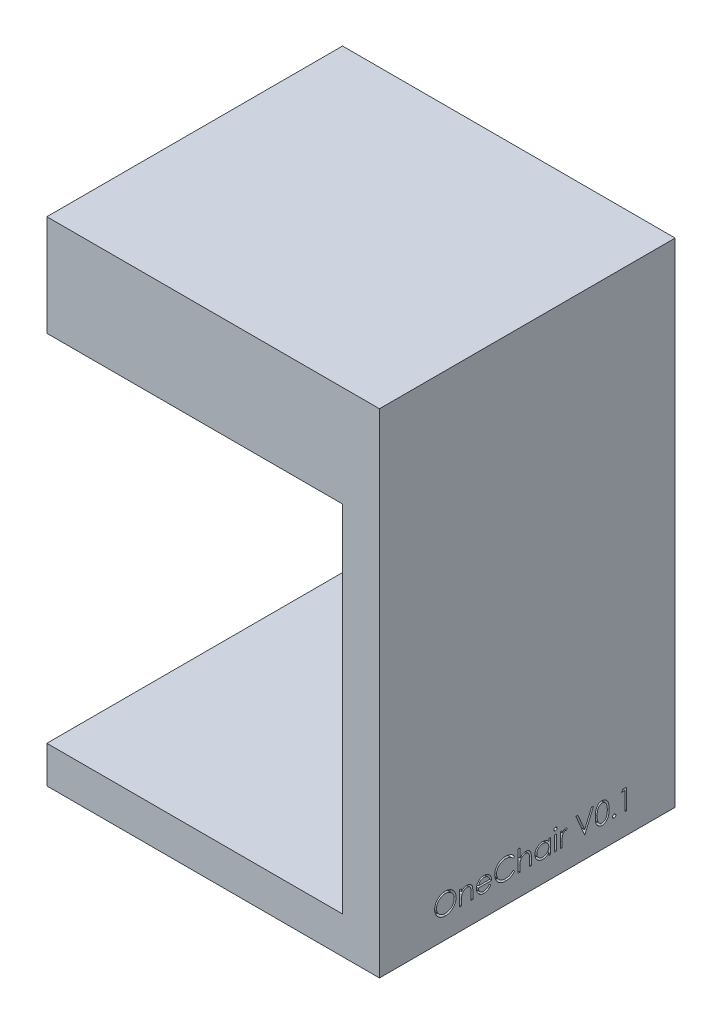
from build123d import *

# Parameters (mm, degrees)
SKETCH1_W           = 50.8
SKETCH1_H           = 50.8
BOSS_EXTRUDE1_DEPTH = 6.35
SKETCH2_W           = 6.35
SKETCH2_H           = 50.8
BOSS_EXTRUDE3_DEPTH = 6.35
SKETCH3_W           = 6.35
SKETCH3_H           = 50.8
BOSS_EXTRUDE4_DEPTH = 61
SKETCH4_W           = 57.15
SKETCH4_H           = 50.8
BOSS_EXTRUDE5_DEPTH = 11
SKETCH7_W           = 57.15
SKETCH7_H           = 50.8
BOSS_EXTRUDE7_DEPTH = 6.35
SKETCH11_W          = 0.314102564
SKETCH11_H          = 2.557692307
CUT_EXTRUDE3_DEPTH  = 1


with BuildPart() as part:
    # Sketch1 → Boss-Extrude1 (new body)
    with BuildSketch(Plane(origin=(0, 0, 0), x_dir=(1, 0, 0), z_dir=(0, 1, 0))):
        Rectangle(SKETCH1_W, SKETCH1_H)
    extrude(amount=BOSS_EXTRUDE1_DEPTH)

    # Sketch2 → Boss-Extrude3 (add)
    with BuildSketch(Plane(origin=(0, 0, 0), x_dir=(1, 0, 0), z_dir=(0, 1, 0))):
        with Locations((28.575, 0)):
            Rectangle(SKETCH2_W, SKETCH2_H)
    extrude(amount=BOSS_EXTRUDE3_DEPTH)

    # Sketch3 → Boss-Extrude4 (add)
    with BuildSketch(Plane(origin=(0, 6.35, 0), x_dir=(1, 0, 0), z_dir=(0, 1, 0))):
        with Locations((28.575, 0)):
            Rectangle(SKETCH3_W, SKETCH3_H)
    extrude(amount=BOSS_EXTRUDE4_DEPTH)

    # Sketch4 → Boss-Extrude5 (add)
    with BuildSketch(Plane(origin=(0, 67.35, 0), x_dir=(1, 0, 0), z_dir=(0, 1, 0))):
        with Locations((3.175, 0)):
            Rectangle(SKETCH4_W, SKETCH4_H)
    extrude(amount=BOSS_EXTRUDE5_DEPTH)

    # Sketch7 → Boss-Extrude7 (add)
    with BuildSketch(Plane(origin=(0, 78.35, 0), x_dir=(1, 0, 0), z_dir=(0, 1, 0))):
        with Locations((3.175, 0)):
            Rectangle(SKETCH7_W, SKETCH7_H)
    extrude(amount=BOSS_EXTRUDE7_DEPTH)

    # Sketch11 → Cut-Extrude3 (cut)
    with BuildSketch(Plane(origin=(31.75, 0, 0), x_dir=(0, 0, -1), z_dir=(1, 0, 0))):
        with BuildLine():
            add(Edge.make_bspline(
                [(-14.101398787, 7.268560163), (-14.036590681, 7.266918684), (-13.909302214, 7.263694683), (-13.722227316, 7.23901558), (-13.543632221, 7.19632019), (-13.372062082, 7.139457207), (-13.209569105, 7.063602822), (-13.054930213, 6.971917673), (-12.908513339, 6.863441215), (-12.772291958, 6.739011988), (-12.647635007, 6.603628534), (-12.537809121, 6.459150624), (-12.445766827, 6.306451822), (-12.37018104, 6.145990991), (-12.31088243, 5.978131023), (-12.269963387, 5.80197702), (-12.243825237, 5.61867033), (-12.240769459, 5.493643465), (-12.239219299, 5.430218817)],
                knots=[0, 0, 0, 0, 0.000194393, 0.000381804, 0.00056479, 0.000744601, 0.000923091, 0.001101652, 0.001283106, 0.001468738, 0.001654324, 0.001834514, 0.002012231, 0.002188181, 0.002365797, 0.002545211, 0.002729936, 0.002920126, 0.002920126, 0.002920126, 0.002920126], degree=3))
            add(Edge.make_bspline(
                [(-12.239219299, 5.430218817), (-12.240769232, 5.367261371), (-12.243824329, 5.243164951), (-12.269993106, 5.061021506), (-12.311034106, 4.88593081), (-12.369630372, 4.718185157), (-12.444855851, 4.557607593), (-12.537511022, 4.404620639), (-12.646652233, 4.259174141), (-12.770859084, 4.122861476), (-12.906260126, 3.997864005), (-13.051490392, 3.888945129), (-13.203283712, 3.795221005), (-13.363593421, 3.720437331), (-13.530293457, 3.66066541), (-13.70487578, 3.61991278), (-13.886522335, 3.593625737), (-14.010393338, 3.590607221), (-14.073353915, 3.589072984)],
                knots=[0, 0, 0, 0, 0.000188789, 0.000372126, 0.000550857, 0.00072758, 0.000904164, 0.001081881, 0.001263191, 0.001448823, 0.00163441, 0.001815159, 0.001992641, 0.002168591, 0.002344885, 0.002522934, 0.002705576, 0.002894365, 0.002894365, 0.002894365, 0.002894365], degree=3))
            add(Edge.make_bspline(
                [(-14.073353915, 3.589072984), (-14.136778234, 3.590622371), (-14.26180445, 3.593676625), (-14.445341485, 3.61985803), (-14.621619229, 3.660799333), (-14.79013358, 3.71930877), (-14.95097851, 3.794926), (-15.104468593, 3.887130379), (-15.24998774, 3.996537521), (-15.386329486, 4.120704095), (-15.511078684, 4.255875647), (-15.61983806, 4.400709902), (-15.712063173, 4.552365359), (-15.787426506, 4.711262883), (-15.847090965, 4.876634326), (-15.887795783, 5.049582803), (-15.914131736, 5.229122309), (-15.917166582, 5.351365207), (-15.918706479, 5.413391894)],
                knots=[0, 0, 0, 0, 0.00019019, 0.000374915, 0.000555011, 0.000732396, 0.00090898, 0.001087298, 0.001268608, 0.00145424, 0.001639827, 0.001819595, 0.001996712, 0.002171394, 0.002346367, 0.002523053, 0.002703612, 0.002889599, 0.002889599, 0.002889599, 0.002889599], degree=3))
            add(Edge.make_bspline(
                [(-15.918706479, 5.413391894), (-15.918171843, 5.455024563), (-15.917109317, 5.537764687), (-15.904317625, 5.660631287), (-15.885755923, 5.781521945), (-15.859154011, 5.900092893), (-15.824362344, 6.016053877), (-15.783310317, 6.13020464), (-15.733170471, 6.241388364), (-15.676489823, 6.350131756), (-15.613228015, 6.454739662), (-15.543352266, 6.553619245), (-15.469316897, 6.647600242), (-15.388153504, 6.734247245), (-15.302537058, 6.816080902), (-15.21107868, 6.891843619), (-15.114336436, 6.96221857), (-15.011894056, 7.025638911), (-14.906275781, 7.082998045), (-14.797399003, 7.132219896), (-14.686742432, 7.174465958), (-14.573787784, 7.208706783), (-14.458835012, 7.235738819), (-14.341633227, 7.254146173), (-14.222275801, 7.266970491), (-14.141864482, 7.268027993), (-14.101398787, 7.268560163)],
                knots=[0, 0, 0, 0, 0.000124849, 0.000248123, 0.000370193, 0.00049164, 0.000612319, 0.000733199, 0.000855287, 0.000977905, 0.001100913, 0.001221706, 0.001340948, 0.001459521, 0.001577551, 0.001696047, 0.001815534, 0.001936153, 0.002057243, 0.002175846, 0.002294342, 0.002412335, 0.002529682, 0.00264829, 0.002768075, 0.00288942, 0.00288942, 0.00288942, 0.00288942], degree=3))
        make_face()
        with BuildLine():
            add(Edge.make_bspline(
                [(-14.085974107, 6.909585804), (-14.119188741, 6.909180914), (-14.185300474, 6.908375004), (-14.28358501, 6.897759289), (-14.380576944, 6.8826294), (-14.476296306, 6.861047879), (-14.570342595, 6.831643826), (-14.663592436, 6.797802918), (-14.75519549, 6.756581828), (-14.844849348, 6.710009123), (-14.931764423, 6.658460202), (-15.013777125, 6.601488435), (-15.091099769, 6.540429881), (-15.163543035, 6.475142044), (-15.230894208, 6.405292442), (-15.294478909, 6.331940006), (-15.351748491, 6.252988115), (-15.404234068, 6.170577708), (-15.451201908, 6.084816127), (-15.492967263, 5.996606265), (-15.527131271, 5.905228578), (-15.554993648, 5.81167442), (-15.578093458, 5.71609196), (-15.592727383, 5.617756112), (-15.603459742, 5.517161), (-15.604219587, 5.449179146), (-15.604603915, 5.414794138)],
                knots=[0, 0, 0, 0, 9.9599e-05, 0.000198245, 0.000296222, 0.00039402, 0.00049227, 0.000591646, 0.000691452, 0.000793368, 0.000894612, 0.000994383, 0.001092713, 0.00119001, 0.001286696, 0.001383657, 0.001480979, 0.001579008, 0.001676595, 0.001774142, 0.001871547, 0.001968922, 0.002066879, 0.00216624, 0.00226698, 0.002370083, 0.002370083, 0.002370083, 0.002370083], degree=3))
            add(Edge.make_bspline(
                [(-15.604603915, 5.414794138), (-15.603329053, 5.364231917), (-15.600821005, 5.264760387), (-15.578863435, 5.118992243), (-15.54504146, 4.978903957), (-15.495184094, 4.845262047), (-15.432833479, 4.716917764), (-15.355806589, 4.59500966), (-15.264547504, 4.479504785), (-15.160883977, 4.371209516), (-15.04756127, 4.272363712), (-14.92722854, 4.185600303), (-14.801174933, 4.112190054), (-14.66907173, 4.052384981), (-14.531624191, 4.004995243), (-14.38794664, 3.972516612), (-14.238996181, 3.951141157), (-14.137465525, 3.949088401), (-14.085974107, 3.948047343)],
                knots=[0, 0, 0, 0, 0.000151605, 0.000298253, 0.000441263, 0.000583229, 0.000725274, 0.000868635, 0.001014928, 0.001166177, 0.001317744, 0.00146543, 0.001610576, 0.001754594, 0.001899821, 0.002045914, 0.002195936, 0.002350312, 0.002350312, 0.002350312, 0.002350312], degree=3))
            add(Edge.make_bspline(
                [(-14.085974107, 3.948047343), (-14.051364606, 3.948522847), (-13.982723569, 3.949465915), (-13.880628047, 3.958964592), (-13.780371835, 3.974196462), (-13.682095555, 3.996127117), (-13.585910744, 4.023574324), (-13.491415941, 4.056182052), (-13.39961765, 4.096863255), (-13.309357813, 4.141811207), (-13.222961571, 4.193051364), (-13.140486039, 4.248089514), (-13.064010059, 4.309058135), (-12.991620987, 4.373375947), (-12.923993298, 4.442339795), (-12.861584314, 4.515860017), (-12.804604182, 4.594400674), (-12.752138535, 4.67668608), (-12.705335273, 4.762682333), (-12.664556174, 4.851212011), (-12.629960058, 4.94205712), (-12.602031553, 5.035348691), (-12.580146091, 5.13090954), (-12.565066171, 5.228867618), (-12.554517733, 5.329026961), (-12.553722655, 5.396770817), (-12.553321864, 5.430919939)],
                knots=[0, 0, 0, 0, 0.000103804, 0.000205874, 0.000307314, 0.000407849, 0.000507719, 0.000607281, 0.000707445, 0.000808723, 0.000909609, 0.001008589, 0.001105934, 0.001202762, 0.001298946, 0.001395452, 0.001491794, 0.001589823, 0.001688026, 0.001785277, 0.001882027, 0.001979402, 0.0020772, 0.002175869, 0.002276609, 0.002379011, 0.002379011, 0.002379011, 0.002379011], degree=3))
            add(Edge.make_bspline(
                [(-12.553321864, 5.430919939), (-12.553722977, 5.464835443), (-12.554518658, 5.532113094), (-12.565061133, 5.631573912), (-12.580162023, 5.728827123), (-12.601924731, 5.823490926), (-12.629974885, 5.915589451), (-12.664562215, 6.005036199), (-12.705347515, 6.092164394), (-12.752155739, 6.176758691), (-12.804771563, 6.257933429), (-12.862265806, 6.335535842), (-12.925631154, 6.408108583), (-12.993057179, 6.477443277), (-13.066228064, 6.542061167), (-13.144812358, 6.601983687), (-13.227856036, 6.658656962), (-13.315783271, 6.709782523), (-13.406527225, 6.756996756), (-13.499641183, 6.797447759), (-13.594070283, 6.831819879), (-13.689574395, 6.861136844), (-13.786957373, 6.882544874), (-13.885561202, 6.897772924), (-13.985249461, 6.90837131), (-14.052292681, 6.909179688), (-14.085974107, 6.909585804)],
                knots=[0, 0, 0, 0, 0.000101701, 0.000201743, 0.00029972, 0.000396835, 0.000492868, 0.000588308, 0.000684288, 0.000781261, 0.000878109, 0.000974304, 0.001070733, 0.001166917, 0.001264269, 0.001363274, 0.001463228, 0.001565678, 0.001668217, 0.001769947, 0.001869982, 0.001969573, 0.002069423, 0.002168785, 0.002268827, 0.002369827, 0.002369827, 0.002369827, 0.002369827], degree=3))
        make_face(mode=Mode.SUBTRACT)
        with BuildLine():
            Line((-11.611014171, 6.236508881), (-11.296911607, 6.236508881))
            Line((-11.296911607, 6.236508881), (-11.296911607, 5.77517074))
            add(Edge.make_bspline(
                [(-11.296911607, 5.77517074), (-11.263373972, 5.817013463), (-11.198293021, 5.898210727), (-11.089908688, 6.004931301), (-10.975364787, 6.092876526), (-10.855362784, 6.16298032), (-10.729739774, 6.215826946), (-10.599261504, 6.253992877), (-10.463146798, 6.276877706), (-10.370582361, 6.279867936), (-10.323754556, 6.281380676)],
                knots=[0, 0, 0, 0, 0.000160777, 0.000311994, 0.000455029, 0.000592958, 0.000727738, 0.000862858, 0.001000022, 0.001140458, 0.001140458, 0.001140458, 0.001140458], degree=3))
            add(Edge.make_bspline(
                [(-10.323754556, 6.281380676), (-10.276423922, 6.279635481), (-10.183786454, 6.276219712), (-10.048908393, 6.249203021), (-9.922934999, 6.203057766), (-9.806315443, 6.139845696), (-9.70118823, 6.061239222), (-9.608863378, 5.969661441), (-9.532500131, 5.864325357), (-9.481302768, 5.766602201), (-9.44757712, 5.679913407), (-9.426344783, 5.605666657), (-9.408313801, 5.522948506), (-9.392682053, 5.432008917), (-9.382104941, 5.332210726), (-9.37376265, 5.223963034), (-9.367783956, 5.107300904), (-9.367546749, 5.026614276), (-9.367424428, 4.985006478)],
                knots=[0, 0, 0, 0, 0.00014192, 0.000277771, 0.000410631, 0.000543023, 0.000674273, 0.000803173, 0.000931629, 0.001063031, 0.00113295, 0.001210382, 0.001294414, 0.001386856, 0.001487045, 0.001595345, 0.001712567, 0.001837375, 0.001837375, 0.001837375, 0.001837375], degree=3))
            Line((-9.367424428, 4.985006478), (-9.367424428, 3.678816574))
            Line((-9.367424428, 3.678816574), (-9.681526992, 3.678816574))
            Line((-9.681526992, 3.678816574), (-9.681526992, 4.881941574))
            add(Edge.make_bspline(
                [(-9.681526992, 4.881941574), (-9.6817202, 4.916764019), (-9.682089774, 4.983373429), (-9.683255421, 5.078742453), (-9.686065227, 5.165229031), (-9.69001354, 5.242626398), (-9.695792571, 5.310860235), (-9.701815202, 5.370069512), (-9.709180179, 5.420179054), (-9.715743092, 5.450344137), (-9.718686447, 5.463872663)],
                knots=[0, 0, 0, 0, 0.00010447, 0.000199832, 0.000286116, 0.000364054, 0.000432294, 0.000491525, 0.000542592, 0.000584118, 0.000584118, 0.000584118, 0.000584118], degree=3))
            add(Edge.make_bspline(
                [(-9.718686447, 5.463872663), (-9.729311978, 5.503583848), (-9.749762839, 5.580015593), (-9.800296822, 5.683689946), (-9.864111003, 5.771888133), (-9.942008852, 5.844064855), (-10.033237928, 5.900235692), (-10.137545071, 5.939209647), (-10.253923711, 5.963585916), (-10.335778094, 5.966013048), (-10.378442056, 5.967278112)],
                knots=[0, 0, 0, 0, 0.000123096, 0.000236922, 0.000343781, 0.000447968, 0.000553428, 0.000663063, 0.000780492, 0.000908329, 0.000908329, 0.000908329, 0.000908329], degree=3))
            add(Edge.make_bspline(
                [(-10.378442056, 5.967278112), (-10.40370974, 5.966802108), (-10.453713833, 5.965860107), (-10.527863804, 5.956408809), (-10.599787978, 5.940950353), (-10.670208187, 5.920081715), (-10.73771598, 5.891419446), (-10.804480272, 5.858890076), (-10.867987036, 5.818341864), (-10.929590433, 5.773151243), (-10.98690324, 5.723072035), (-11.040231579, 5.670227525), (-11.087769599, 5.613951921), (-11.130838274, 5.555151974), (-11.168016538, 5.493020136), (-11.200469626, 5.428155829), (-11.228005321, 5.360473681), (-11.241688013, 5.313498619), (-11.248534203, 5.289994458)],
                knots=[0, 0, 0, 0, 7.5773e-05, 0.000149953, 0.000223797, 0.000296325, 0.00036989, 0.000443574, 0.000518859, 0.000595564, 0.000672601, 0.000746967, 0.000820581, 0.000893366, 0.000965391, 0.001037508, 0.001110807, 0.001184211, 0.001184211, 0.001184211, 0.001184211], degree=3))
            add(Edge.make_bspline(
                [(-11.248534203, 5.289994458), (-11.252473852, 5.272739255), (-11.261050261, 5.235175581), (-11.270313441, 5.173531161), (-11.278721016, 5.102221186), (-11.285757975, 5.021328869), (-11.290063391, 4.930570994), (-11.294757788, 4.830335157), (-11.296466849, 4.720221668), (-11.296759203, 4.643559975), (-11.296911607, 4.603596221)],
                knots=[0, 0, 0, 0, 5.3082e-05, 0.000115557, 0.000186868, 0.0002685, 0.000359077, 0.000459426, 0.000569522, 0.000689416, 0.000689416, 0.000689416, 0.000689416], degree=3))
            Line((-11.296911607, 4.603596221), (-11.296911607, 3.678816574))
            Line((-11.296911607, 3.678816574), (-11.611014171, 3.678816574))
            Line((-11.611014171, 3.678816574), (-11.611014171, 6.236508881))
        make_face()
        with BuildLine():
            Line((-6.550317056, 4.486508881), (-6.271270582, 4.339974426))
            add(Edge.make_bspline(
                [(-6.271270582, 4.339974426), (-6.293507177, 4.300531095), (-6.336770785, 4.223789992), (-6.411171533, 4.118358132), (-6.489163606, 4.023510416), (-6.574267574, 3.941780762), (-6.663937253, 3.870529377), (-6.758669907, 3.808191552), (-6.858958725, 3.755073032), (-6.96480845, 3.710320504), (-7.077108001, 3.67591101), (-7.196129518, 3.651606789), (-7.322101013, 3.63658352), (-7.408447193, 3.634838379), (-7.452660806, 3.633944779)],
                knots=[0, 0, 0, 0, 0.000135759, 0.000264133, 0.000386579, 0.000503597, 0.000617365, 0.000729763, 0.000843304, 0.000957371, 0.001074023, 0.001195027, 0.001321389, 0.001453992, 0.001453992, 0.001453992, 0.001453992], degree=3))
            add(Edge.make_bspline(
                [(-7.452660806, 3.633944779), (-7.501802783, 3.635091954), (-7.597664545, 3.637329761), (-7.737204292, 3.656622225), (-7.868583711, 3.688094584), (-7.991795414, 3.732060126), (-8.106537667, 3.78948745), (-8.213038521, 3.859446931), (-8.311858047, 3.941579186), (-8.399882256, 4.03659563), (-8.479126139, 4.138277587), (-8.549051959, 4.244233471), (-8.60750939, 4.354196696), (-8.655062, 4.46746722), (-8.693466865, 4.583331113), (-8.720233569, 4.702842581), (-8.735663317, 4.825678165), (-8.738027763, 4.908775501), (-8.739219299, 4.95065151)],
                knots=[0, 0, 0, 0, 0.000147371, 0.000287478, 0.000421649, 0.000552053, 0.000679042, 0.000805636, 0.000933558, 0.00106351, 0.001193382, 0.001319977, 0.001443869, 0.001566405, 0.001688128, 0.001809576, 0.001933238, 0.002058864, 0.002058864, 0.002058864, 0.002058864], degree=3))
            add(Edge.make_bspline(
                [(-8.739219299, 4.95065151), (-8.738160158, 4.98994634), (-8.73606108, 5.067823505), (-8.722830293, 5.183089049), (-8.699381999, 5.295117502), (-8.667205676, 5.40400195), (-8.625654429, 5.509560084), (-8.57482221, 5.611856147), (-8.514629832, 5.710781287), (-8.468157159, 5.773184421), (-8.444748146, 5.804617856)],
                knots=[0, 0, 0, 0, 0.000117891, 0.000233644, 0.000347498, 0.000460856, 0.000573868, 0.000687374, 0.000803169, 0.000920699, 0.000920699, 0.000920699, 0.000920699], degree=3))
            add(Edge.make_bspline(
                [(-8.444748146, 5.804617856), (-8.413040463, 5.842486726), (-8.350629516, 5.917024876), (-8.245073161, 6.014963202), (-8.130772965, 6.097006977), (-8.009161338, 6.165014113), (-7.878824864, 6.21668776), (-7.741515573, 6.255195343), (-7.595669987, 6.276773354), (-7.495964766, 6.279821187), (-7.444948466, 6.281380676)],
                knots=[0, 0, 0, 0, 0.000148071, 0.000291452, 0.00043058, 0.000569298, 0.000708346, 0.00085021, 0.000996268, 0.001149307, 0.001149307, 0.001149307, 0.001149307], degree=3))
            add(Edge.make_bspline(
                [(-7.444948466, 6.281380676), (-7.392500861, 6.280026627), (-7.289610615, 6.277370292), (-7.139578494, 6.252743959), (-6.997617777, 6.213691404), (-6.863785273, 6.158537614), (-6.738067412, 6.087378062), (-6.621281363, 5.99923622), (-6.51142985, 5.896818133), (-6.447521271, 5.818054924), (-6.415000549, 5.777975228)],
                knots=[0, 0, 0, 0, 0.000157241, 0.00030847, 0.000454763, 0.000598116, 0.000741606, 0.000886879, 0.001036172, 0.001190853, 0.001190853, 0.001190853, 0.001190853], degree=3))
            add(Edge.make_bspline(
                [(-6.415000549, 5.777975228), (-6.392873611, 5.747771646), (-6.348767018, 5.687565527), (-6.293519918, 5.58939437), (-6.245562523, 5.486683776), (-6.207229562, 5.377773479), (-6.176190061, 5.263953899), (-6.153733242, 5.144411354), (-6.140563624, 5.019181443), (-6.137974926, 4.933854887), (-6.136655197, 4.890355035)],
                knots=[0, 0, 0, 0, 0.000112234, 0.000223721, 0.000337279, 0.000451932, 0.000569628, 0.000690912, 0.000816421, 0.00094695, 0.00094695, 0.00094695, 0.00094695], degree=3))
            Line((-6.136655197, 4.890355035), (-8.425116735, 4.890355035))
            add(Edge.make_bspline(
                [(-8.425116735, 4.890355035), (-8.423577129, 4.856654571), (-8.420549555, 4.790383967), (-8.406434412, 4.693413184), (-8.384185638, 4.601039842), (-8.352916575, 4.5139568), (-8.31504973, 4.431026673), (-8.268664013, 4.352864636), (-8.213324459, 4.279826705), (-8.15159876, 4.211259568), (-8.082891665, 4.150198807), (-8.010608918, 4.09554703), (-7.933715353, 4.049741434), (-7.852817269, 4.012561544), (-7.768045484, 3.983455228), (-7.679373289, 3.963587407), (-7.586975172, 3.9502803), (-7.523989438, 3.948800635), (-7.491923626, 3.948047343)],
                knots=[0, 0, 0, 0, 0.000101159, 0.000198924, 0.000293472, 0.000385722, 0.000476069, 0.000566611, 0.000657757, 0.000750573, 0.000842919, 0.000933083, 0.001022062, 0.001110842, 0.001199752, 0.001290403, 0.001383113, 0.001479259, 0.001479259, 0.001479259, 0.001479259], degree=3))
            add(Edge.make_bspline(
                [(-7.491923626, 3.948047343), (-7.460572479, 3.9486554), (-7.398365788, 3.949861901), (-7.305724931, 3.961593812), (-7.214585403, 3.980564087), (-7.12532442, 4.006454077), (-7.039753574, 4.038030929), (-6.960508024, 4.076133787), (-6.887627808, 4.118283534), (-6.819510842, 4.166493209), (-6.753439848, 4.225501396), (-6.687897362, 4.299137117), (-6.617620709, 4.386224645), (-6.573631116, 4.451770311), (-6.550317056, 4.486508881)],
                knots=[0, 0, 0, 0, 9.4016e-05, 0.000186545, 0.000279636, 0.000373054, 0.000465125, 0.000552934, 0.000636508, 0.000717442, 0.000802858, 0.000901616, 0.001012865, 0.001138311, 0.001138311, 0.001138311, 0.001138311], degree=3))
        make_face()
        with BuildLine():
            add(Edge.make_bspline(
                [(-6.450757761, 5.204457599), (-6.462254386, 5.246120473), (-6.484381687, 5.326308094), (-6.530618052, 5.437348984), (-6.582689592, 5.536036885), (-6.644311324, 5.621616518), (-6.714130049, 5.697620031), (-6.794775232, 5.764038616), (-6.885211125, 5.823456067), (-6.984970266, 5.873608567), (-7.090612051, 5.916298426), (-7.201218243, 5.944923541), (-7.314076031, 5.964533084), (-7.390410317, 5.966359192), (-7.428822665, 5.967278112)],
                knots=[0, 0, 0, 0, 0.000129543, 0.000249328, 0.000360065, 0.000463575, 0.000564789, 0.000668832, 0.000776175, 0.000888744, 0.001003316, 0.001117263, 0.001230914, 0.001346035, 0.001346035, 0.001346035, 0.001346035], degree=3))
            add(Edge.make_bspline(
                [(-7.428822665, 5.967278112), (-7.460172103, 5.966666441), (-7.522143352, 5.965457295), (-7.613444421, 5.953987165), (-7.70112412, 5.93502732), (-7.785829407, 5.909062364), (-7.866450276, 5.874453761), (-7.944645044, 5.833870535), (-8.01842544, 5.784328951), (-8.064566735, 5.746570096), (-8.087877152, 5.727494458)],
                knots=[0, 0, 0, 0, 9.4016e-05, 0.000185849, 0.000275511, 0.000362884, 0.000451173, 0.00053836, 0.000626838, 0.000717174, 0.000717174, 0.000717174, 0.000717174], degree=3))
            add(Edge.make_bspline(
                [(-8.087877152, 5.727494458), (-8.104570434, 5.712400143), (-8.138353568, 5.681852927), (-8.18349409, 5.62922372), (-8.226714562, 5.572472158), (-8.266048215, 5.509427033), (-8.302125802, 5.440806254), (-8.335885779, 5.367188619), (-8.366272191, 5.288015489), (-8.383368301, 5.23284305), (-8.392164011, 5.204457599)],
                knots=[0, 0, 0, 0, 6.7454e-05, 0.00013651, 0.000207604, 0.000281328, 0.000359112, 0.000440057, 0.000524171, 0.000613305, 0.000613305, 0.000613305, 0.000613305], degree=3))
            Line((-8.392164011, 5.204457599), (-6.450757761, 5.204457599))
        make_face(mode=Mode.SUBTRACT)
        with BuildLine():
            Line((-2.187937248, 6.53658901), (-2.462776992, 6.326252471))
            add(Edge.make_bspline(
                [(-2.462776992, 6.326252471), (-2.48238288, 6.349618441), (-2.521330327, 6.396035357), (-2.58398953, 6.461214901), (-2.649291172, 6.522280163), (-2.717210294, 6.579522042), (-2.788969413, 6.630938808), (-2.862830212, 6.679209911), (-2.940028257, 6.722477649), (-3.046779992, 6.774940635), (-3.18642784, 6.82968679), (-3.362222679, 6.875590021), (-3.545733777, 6.904811197), (-3.670931377, 6.907976038), (-3.734611928, 6.909585804)],
                knots=[0, 0, 0, 0, 9.1485e-05, 0.000181737, 0.000271024, 0.000359627, 0.000447979, 0.000535687, 0.000624217, 0.000713268, 0.000892422, 0.00107303, 0.001257466, 0.001448389, 0.001448389, 0.001448389, 0.001448389], degree=3))
            add(Edge.make_bspline(
                [(-3.734611928, 6.909585804), (-3.769695227, 6.909181842), (-3.83953622, 6.908377666), (-3.943184693, 6.897768541), (-4.044897744, 6.882857331), (-4.14460921, 6.860732008), (-4.242192169, 6.832759389), (-4.338284571, 6.799333975), (-4.431495171, 6.757979135), (-4.523113409, 6.712270875), (-4.61089262, 6.66064343), (-4.693947668, 6.604330078), (-4.771975636, 6.543960982), (-4.845038248, 6.479309875), (-4.913210196, 6.410667915), (-4.975997507, 6.337303573), (-5.033182917, 6.2594514), (-5.085899942, 6.178137992), (-5.133112676, 6.093600201), (-5.172642555, 6.00552513), (-5.207647677, 5.915421027), (-5.23534692, 5.822269866), (-5.257271437, 5.7267271), (-5.2723991, 5.628536312), (-5.282887571, 5.527902633), (-5.283687748, 5.45969332), (-5.284091094, 5.425310965)],
                knots=[0, 0, 0, 0, 0.000105206, 0.000209435, 0.000312261, 0.00041348, 0.000515565, 0.000616682, 0.000718413, 0.000821258, 0.000923708, 0.001023662, 0.001122111, 0.001219464, 0.00131614, 0.001412112, 0.001508869, 0.001605718, 0.001702691, 0.001799013, 0.001895107, 0.001992482, 0.002090281, 0.00218895, 0.002290387, 0.00239349, 0.00239349, 0.00239349, 0.00239349], degree=3))
            add(Edge.make_bspline(
                [(-5.284091094, 5.425310965), (-5.282829275, 5.373579645), (-5.280351861, 5.27201206), (-5.258303527, 5.123241449), (-5.224798436, 4.980720776), (-5.174582859, 4.845340933), (-5.112663808, 4.715432575), (-5.034423197, 4.593193722), (-4.943806659, 4.476777157), (-4.83953224, 4.36893421), (-4.725126424, 4.270420484), (-4.602378512, 4.183669903), (-4.471594225, 4.11135502), (-4.334217594, 4.051179074), (-4.18919148, 4.004922346), (-4.036776678, 3.972358223), (-3.877304683, 3.951116042), (-3.768335283, 3.949082354), (-3.712877152, 3.948047343)],
                knots=[0, 0, 0, 0, 0.000155106, 0.000304531, 0.000450265, 0.000593548, 0.000736853, 0.000881182, 0.001028026, 0.001178769, 0.001330408, 0.001480379, 0.001628835, 0.001777978, 0.001929641, 0.002084627, 0.002245075, 0.00241136, 0.00241136, 0.00241136, 0.00241136], degree=3))
            add(Edge.make_bspline(
                [(-3.712877152, 3.948047343), (-3.651774463, 3.949736123), (-3.531509754, 3.953060045), (-3.355141728, 3.981219294), (-3.186305962, 4.026877212), (-3.024993376, 4.090775135), (-2.871658729, 4.173840422), (-2.726062069, 4.2745383), (-2.588080499, 4.393826633), (-2.505109216, 4.484909761), (-2.462776992, 4.531380676)],
                knots=[0, 0, 0, 0, 0.00018322, 0.00036062, 0.000534275, 0.000707044, 0.000879893, 0.001056289, 0.001237208, 0.001425665, 0.001425665, 0.001425665, 0.001425665], degree=3))
            Line((-2.462776992, 4.531380676), (-2.187937248, 4.323147503))
            add(Edge.make_bspline(
                [(-2.187937248, 4.323147503), (-2.210055358, 4.294609051), (-2.254185633, 4.237668845), (-2.32564365, 4.157397135), (-2.400920948, 4.0818931), (-2.480576658, 4.011765479), (-2.563694449, 3.945611013), (-2.651766762, 3.885309182), (-2.743635794, 3.830018297), (-2.838990273, 3.779391373), (-2.937728886, 3.734474126), (-3.039733321, 3.696020358), (-3.144563896, 3.662895469), (-3.252225405, 3.635643532), (-3.362941162, 3.614372448), (-3.476311636, 3.600152773), (-3.592581511, 3.590410859), (-3.671022932, 3.589522943), (-3.710773787, 3.589072984)],
                knots=[0, 0, 0, 0, 0.000108293, 0.000216068, 0.000322162, 0.000427957, 0.000534281, 0.00064066, 0.000747915, 0.000855806, 0.000964371, 0.001073102, 0.001182643, 0.001294024, 0.001406092, 0.001520624, 0.001636667, 0.001755891, 0.001755891, 0.001755891, 0.001755891], degree=3))
            add(Edge.make_bspline(
                [(-3.710773787, 3.589072984), (-3.748417454, 3.589334977), (-3.822853144, 3.589853034), (-3.932751895, 3.598245202), (-4.039741476, 3.609694939), (-4.143516102, 3.62693507), (-4.244642077, 3.64727941), (-4.342202662, 3.674550666), (-4.437157872, 3.705099833), (-4.529126213, 3.74100482), (-4.618185913, 3.781521002), (-4.704049724, 3.827312561), (-4.786678156, 3.877994426), (-4.866883577, 3.932449436), (-4.943481161, 3.992426738), (-5.017134686, 4.057093373), (-5.088257162, 4.126231383), (-5.132259847, 4.176086237), (-5.154383562, 4.201152311)],
                knots=[0, 0, 0, 0, 0.0001129, 0.000223246, 0.000330481, 0.000435603, 0.000538732, 0.000639764, 0.000739316, 0.000837878, 0.000935767, 0.001032686, 0.001129604, 0.00122645, 0.001323362, 0.001421241, 0.001520399, 0.001620667, 0.001620667, 0.001620667, 0.001620667], degree=3))
            add(Edge.make_bspline(
                [(-5.154383562, 4.201152311), (-5.189819206, 4.2446935), (-5.260262683, 4.33125021), (-5.350388366, 4.471536191), (-5.427535921, 4.6180044), (-5.489911842, 4.771424329), (-5.538674575, 4.931451716), (-5.57245577, 5.098167231), (-5.594407375, 5.271415173), (-5.596917664, 5.389251962), (-5.598193658, 5.449149106)],
                knots=[0, 0, 0, 0, 0.000168306, 0.00033458, 0.000499224, 0.000664315, 0.00083066, 0.00100034, 0.001174094, 0.001353718, 0.001353718, 0.001353718, 0.001353718], degree=3))
            add(Edge.make_bspline(
                [(-5.598193658, 5.449149106), (-5.596638465, 5.512104559), (-5.593578719, 5.635965484), (-5.567582923, 5.817739437), (-5.525764127, 5.991890836), (-5.466367238, 6.158094581), (-5.391061887, 6.317224861), (-5.298035273, 6.468066066), (-5.188368131, 6.611582865), (-5.062920563, 6.745597617), (-4.925353228, 6.868136969), (-4.778034414, 6.975943173), (-4.621252467, 7.065660689), (-4.456734616, 7.140656851), (-4.283248934, 7.198301315), (-4.101165565, 7.238654501), (-3.91082665, 7.263771618), (-3.780964224, 7.266946825), (-3.714980517, 7.268560163)],
                knots=[0, 0, 0, 0, 0.000188789, 0.000371431, 0.000549644, 0.000725278, 0.00089996, 0.001076844, 0.001255917, 0.001440951, 0.001626689, 0.001807878, 0.001987546, 0.002167657, 0.002349462, 0.002534866, 0.002726448, 0.002924344, 0.002924344, 0.002924344, 0.002924344], degree=3))
            add(Edge.make_bspline(
                [(-3.714980517, 7.268560163), (-3.674766046, 7.268078025), (-3.595165548, 7.267123681), (-3.477412896, 7.257817539), (-3.362770569, 7.242303933), (-3.251159587, 7.221187863), (-3.142036971, 7.194980542), (-3.03623673, 7.160840243), (-2.933138043, 7.121803712), (-2.833391135, 7.076845246), (-2.737474585, 7.026378505), (-2.645418266, 6.970962881), (-2.557953407, 6.910667076), (-2.474464559, 6.8460039), (-2.396348348, 6.775605341), (-2.321386869, 6.701407745), (-2.252125791, 6.621273921), (-2.209372596, 6.564868987), (-2.187937248, 6.53658901)],
                knots=[0, 0, 0, 0, 0.000120626, 0.000238766, 0.000354085, 0.000467531, 0.000579423, 0.000690512, 0.000800803, 0.000910007, 0.001018518, 0.001125773, 0.001232152, 0.001337058, 0.001442329, 0.001547432, 0.001653292, 0.001759736, 0.001759736, 0.001759736, 0.001759736], degree=3))
        make_face()
        with BuildLine():
            Line((-1.55973212, 7.268560163), (-1.245629556, 7.268560163))
            Line((-1.245629556, 7.268560163), (-1.245629556, 5.753435965))
            add(Edge.make_bspline(
                [(-1.245629556, 5.753435965), (-1.211912254, 5.795579947), (-1.14626294, 5.877636439), (-1.035766824, 5.98469763), (-0.922295951, 6.077496252), (-0.801931142, 6.151366709), (-0.676880621, 6.209723252), (-0.546616977, 6.251110899), (-0.411116006, 6.276561995), (-0.319090856, 6.279760413), (-0.272472505, 6.281380676)],
                knots=[0, 0, 0, 0, 0.000161765, 0.000314964, 0.000460595, 0.000600688, 0.000737457, 0.000873601, 0.001009745, 0.001149522, 0.001149522, 0.001149522, 0.001149522], degree=3))
            add(Edge.make_bspline(
                [(-0.272472505, 6.281380676), (-0.225142112, 6.279635246), (-0.132505116, 6.276219018), (0.002376346, 6.249205637), (0.128337221, 6.203048199), (0.245003064, 6.139881174), (0.349827761, 6.061208347), (0.442677525, 5.970376824), (0.518518324, 5.865102906), (0.570117441, 5.767846652), (0.603690849, 5.681307898), (0.624942675, 5.607071386), (0.642961874, 5.524349472), (0.658661609, 5.43318474), (0.669125191, 5.333139569), (0.677529809, 5.224665314), (0.683506263, 5.107768196), (0.683737868, 5.026847947), (0.683857624, 4.985006478)],
                knots=[0, 0, 0, 0, 0.00014192, 0.000277771, 0.000410631, 0.000543023, 0.000674273, 0.000802678, 0.000931134, 0.001061916, 0.001131835, 0.001209267, 0.001293299, 0.001385741, 0.001486627, 0.001594927, 0.001712148, 0.001837657, 0.001837657, 0.001837657, 0.001837657], degree=3))
            Line((0.683857624, 4.985006478), (0.683857624, 3.678816574))
            Line((0.683857624, 3.678816574), (0.369755059, 3.678816574))
            Line((0.369755059, 3.678816574), (0.369755059, 4.881941574))
            add(Edge.make_bspline(
                [(0.369755059, 4.881941574), (0.369564756, 4.916764243), (0.369200739, 4.983374084), (0.367997394, 5.078740192), (0.365311179, 5.165236327), (0.360970353, 5.242585278), (0.356405046, 5.310894882), (0.350121728, 5.370065936), (0.342811494, 5.420179711), (0.336242713, 5.45034434), (0.333296726, 5.463872663)],
                knots=[0, 0, 0, 0, 0.00010447, 0.000199832, 0.000286116, 0.000364054, 0.00043224, 0.000491471, 0.000542538, 0.000584064, 0.000584064, 0.000584064, 0.000584064], degree=3))
            add(Edge.make_bspline(
                [(0.333296726, 5.463872663), (0.321872481, 5.503566927), (0.299909436, 5.579878918), (0.248861459, 5.683541328), (0.185102448, 5.771926069), (0.107255187, 5.843840357), (0.016696822, 5.900251896), (-0.087163142, 5.939319678), (-0.20334721, 5.9635674), (-0.285198682, 5.966006704), (-0.327861126, 5.967278112)],
                knots=[0, 0, 0, 0, 0.000123724, 0.000237858, 0.000344716, 0.000448903, 0.000553767, 0.000662748, 0.000780177, 0.000908014, 0.000908014, 0.000908014, 0.000908014], degree=3))
            add(Edge.make_bspline(
                [(-0.327861126, 5.967278112), (-0.3531289, 5.966802286), (-0.40313317, 5.965860638), (-0.477281836, 5.956406739), (-0.549210899, 5.940958021), (-0.619613077, 5.920053482), (-0.686996275, 5.891607946), (-0.7533246, 5.858677756), (-0.816718809, 5.818369501), (-0.878304626, 5.773143734), (-0.935622159, 5.723073974), (-0.988949274, 5.670227019), (-1.036487615, 5.613952055), (-1.079556206, 5.555151939), (-1.116734491, 5.493020145), (-1.149187573, 5.428155827), (-1.17672327, 5.360473681), (-1.190405962, 5.31349862), (-1.197252152, 5.289994458)],
                knots=[0, 0, 0, 0, 7.5773e-05, 0.000149953, 0.000223797, 0.000296325, 0.00036989, 0.000442948, 0.000518233, 0.000594938, 0.000671975, 0.00074634, 0.000819955, 0.00089274, 0.000964764, 0.001036881, 0.001110181, 0.001183585, 0.001183585, 0.001183585, 0.001183585], degree=3))
            add(Edge.make_bspline(
                [(-1.197252152, 5.289994458), (-1.201191579, 5.272973507), (-1.209776076, 5.23588276), (-1.219090909, 5.174708436), (-1.227428706, 5.103622064), (-1.234477256, 5.022731464), (-1.238800342, 4.931740222), (-1.243458583, 4.831269263), (-1.245192597, 4.720689242), (-1.24547955, 4.643793735), (-1.245629556, 4.603596221)],
                knots=[0, 0, 0, 0, 5.2397e-05, 0.000114179, 0.000185491, 0.000267122, 0.0003577, 0.000458749, 0.000568845, 0.00068944, 0.00068944, 0.00068944, 0.00068944], degree=3))
            Line((-1.245629556, 4.603596221), (-1.245629556, 3.678816574))
            Line((-1.245629556, 3.678816574), (-1.55973212, 3.678816574))
            Line((-1.55973212, 3.678816574), (-1.55973212, 7.268560163))
        make_face()
        with BuildLine():
            Line((4.004370444, 6.236508881), (4.004370444, 3.678816574))
            Line((4.004370444, 3.678816574), (3.69026788, 3.678816574))
            Line((3.69026788, 3.678816574), (3.69026788, 4.121224426))
            add(Edge.make_bspline(
                [(3.69026788, 4.121224426), (3.654849089, 4.081184832), (3.585728874, 4.003047061), (3.470287756, 3.900964889), (3.347919578, 3.816586567), (3.219218257, 3.748436651), (3.084300014, 3.697244595), (2.943463926, 3.660858436), (2.796652546, 3.637464601), (2.696400191, 3.635128579), (2.645596406, 3.633944779)],
                knots=[0, 0, 0, 0, 0.000160263, 0.000312755, 0.000460949, 0.000605216, 0.000748578, 0.000892786, 0.001041028, 0.001193333, 0.001193333, 0.001193333, 0.001193333], degree=3))
            add(Edge.make_bspline(
                [(2.645596406, 3.633944779), (2.600428452, 3.635171151), (2.511355247, 3.637589612), (2.38032617, 3.656351915), (2.25423392, 3.686482537), (2.132959348, 3.728383426), (2.017287202, 3.783964248), (1.906227106, 3.850505496), (1.800354414, 3.929746326), (1.701282875, 4.020334354), (1.610050874, 4.118729342), (1.529989602, 4.223674888), (1.463236522, 4.334717192), (1.407416441, 4.450450346), (1.364420097, 4.571765266), (1.334446462, 4.698242434), (1.315706016, 4.829732307), (1.313288555, 4.91927183), (1.312062752, 4.964673945)],
                knots=[0, 0, 0, 0, 0.000135464, 0.00026714, 0.000396211, 0.000523931, 0.000651257, 0.000780517, 0.000911767, 0.001047265, 0.00118272, 0.001313831, 0.001442491, 0.001570752, 0.001698704, 0.001827775, 0.001960146, 0.00209631, 0.00209631, 0.00209631, 0.00209631], degree=3))
            add(Edge.make_bspline(
                [(1.312062752, 4.964673945), (1.313315723, 5.009137649), (1.31579278, 5.097039992), (1.334246, 5.22631869), (1.365277009, 5.350836951), (1.408824856, 5.470193894), (1.464666811, 5.584533944), (1.532594898, 5.693937969), (1.612614023, 5.798707367), (1.70486643, 5.896378594), (1.8048012, 5.986599208), (1.911709931, 6.065008253), (2.022933212, 6.132725102), (2.140196223, 6.186378579), (2.261763328, 6.229787683), (2.388716773, 6.259820651), (2.520528352, 6.277517972), (2.610018844, 6.280080737), (2.655412111, 6.281380676)],
                knots=[0, 0, 0, 0, 0.000133363, 0.00026365, 0.000390846, 0.000517716, 0.000644083, 0.000771912, 0.000903449, 0.001038867, 0.001174416, 0.001306792, 0.001436052, 0.00156435, 0.001692963, 0.001822716, 0.001954992, 0.002091156, 0.002091156, 0.002091156, 0.002091156], degree=3))
            add(Edge.make_bspline(
                [(2.655412111, 6.281380676), (2.70761197, 6.279942925), (2.80997343, 6.277123562), (2.959701439, 6.253660834), (3.101345917, 6.214022367), (3.236000269, 6.160104869), (3.363180955, 6.08845614), (3.481683939, 5.998076179), (3.592749423, 5.889534992), (3.657129714, 5.806164548), (3.69026788, 5.76325167)],
                knots=[0, 0, 0, 0, 0.00015654, 0.000306968, 0.000453261, 0.000596998, 0.000741098, 0.000889738, 0.001042937, 0.001205434, 0.001205434, 0.001205434, 0.001205434], degree=3))
            Line((3.69026788, 5.76325167), (3.69026788, 6.236508881))
            Line((3.69026788, 6.236508881), (4.004370444, 6.236508881))
        make_face()
        with BuildLine():
            add(Edge.make_bspline(
                [(2.659618842, 5.967278112), (2.613704504, 5.965644474), (2.523076904, 5.962419933), (2.390032902, 5.937246438), (2.262719488, 5.895361844), (2.141773413, 5.838079943), (2.029105197, 5.766051206), (1.928411526, 5.678929823), (1.838868824, 5.579092809), (1.76356056, 5.466990698), (1.702170063, 5.346812607), (1.659003031, 5.221188169), (1.630533784, 5.092383192), (1.627625263, 5.005020506), (1.626165316, 4.961168337)],
                knots=[0, 0, 0, 0, 0.000137677, 0.000271753, 0.000404561, 0.000538791, 0.000672205, 0.000804452, 0.00093703, 0.001073348, 0.00120849, 0.001340643, 0.001470999, 0.001602378, 0.001602378, 0.001602378, 0.001602378], degree=3))
            add(Edge.make_bspline(
                [(1.626165316, 4.961168337), (1.628030209, 4.917578229), (1.631752686, 4.830568873), (1.65850338, 4.701588297), (1.703383254, 4.575934255), (1.764625317, 4.454673261), (1.841311941, 4.342089161), (1.930200594, 4.240349038), (2.032150875, 4.15285945), (2.145078382, 4.079621876), (2.265686353, 4.020459355), (2.392520284, 3.979293716), (2.523195922, 3.952715935), (2.612048256, 3.949611458), (2.656814354, 3.948047343)],
                knots=[0, 0, 0, 0, 0.000130727, 0.000260941, 0.000393327, 0.000530037, 0.000667328, 0.000800955, 0.000934191, 0.001068956, 0.001203792, 0.001335934, 0.001468075, 0.001602253, 0.001602253, 0.001602253, 0.001602253], degree=3))
            add(Edge.make_bspline(
                [(2.656814354, 3.948047343), (2.702260857, 3.949707307), (2.792649444, 3.95300881), (2.926088152, 3.978290076), (3.055583114, 4.020058874), (3.179370343, 4.077958001), (3.294686474, 4.149715357), (3.398184351, 4.233722448), (3.48570032, 4.331425632), (3.559892929, 4.438802085), (3.618068346, 4.556514081), (3.660444405, 4.681848272), (3.685498311, 4.81480902), (3.688656041, 4.905672947), (3.69026788, 4.952053753)],
                knots=[0, 0, 0, 0, 0.000136278, 0.000271043, 0.000405851, 0.000543552, 0.000679927, 0.000812429, 0.000941985, 0.001072088, 0.00120284, 0.001334538, 0.001467925, 0.001607002, 0.001607002, 0.001607002, 0.001607002], degree=3))
            add(Edge.make_bspline(
                [(3.69026788, 4.952053753), (3.689308224, 4.987391584), (3.687419316, 5.056947617), (3.672988747, 5.159075135), (3.65003382, 5.256808861), (3.61768765, 5.35025155), (3.575196366, 5.438886565), (3.5239486, 5.523350325), (3.46304315, 5.603203537), (3.393460454, 5.677346608), (3.317295252, 5.74497307), (3.236700711, 5.805337311), (3.150721964, 5.854926083), (3.060804927, 5.895967355), (2.966793593, 5.928626505), (2.867922973, 5.950414199), (2.765243986, 5.96537452), (2.69519793, 5.9666369), (2.659618842, 5.967278112)],
                knots=[0, 0, 0, 0, 0.000105983, 0.000208608, 0.000308773, 0.00040678, 0.000504626, 0.000603105, 0.000702667, 0.00080535, 0.000907651, 0.001007914, 0.001106881, 0.00120477, 0.001304102, 0.001404791, 0.00150811, 0.001614764, 0.001614764, 0.001614764, 0.001614764], degree=3))
        make_face(mode=Mode.SUBTRACT)
        with BuildLine():
            add(Edge.make_bspline(
                [(4.833096406, 7.313431958), (4.852587721, 7.312527806), (4.890755461, 7.310757302), (4.945948729, 7.295595825), (4.996205741, 7.269896139), (5.040783474, 7.235416458), (5.079035361, 7.194867015), (5.105816071, 7.147606047), (5.123028467, 7.096547408), (5.125107022, 7.060932319), (5.126165316, 7.042798945)],
                knots=[0, 0, 0, 0, 5.84e-05, 0.000114358, 0.000170171, 0.000226684, 0.000282761, 0.000336156, 0.000388483, 0.00044276, 0.00044276, 0.00044276, 0.00044276], degree=3))
            add(Edge.make_bspline(
                [(5.126165316, 7.042798945), (5.125083156, 7.025136292), (5.122943854, 6.990219317), (5.105829366, 6.940045845), (5.078807128, 6.893441562), (5.040808002, 6.852970852), (4.996199241, 6.818510232), (4.945950456, 6.792805493), (4.890755007, 6.777645355), (4.852587568, 6.775874667), (4.833096406, 6.77497042)],
                knots=[0, 0, 0, 0, 5.2882e-05, 0.000104542, 0.000157332, 0.000213408, 0.000269922, 0.000325735, 0.000381693, 0.000440092, 0.000440092, 0.000440092, 0.000440092], degree=3))
            add(Edge.make_bspline(
                [(4.833096406, 6.77497042), (4.81382813, 6.77584014), (4.77632495, 6.777532937), (4.721958108, 6.793102955), (4.672129619, 6.818519028), (4.627464946, 6.852745213), (4.590234753, 6.89369011), (4.563136427, 6.940017404), (4.546061465, 6.990226558), (4.543916837, 7.025138725), (4.542831983, 7.042798945)],
                knots=[0, 0, 0, 0, 5.7701e-05, 0.000112308, 0.000168121, 0.000224634, 0.000280239, 0.000333029, 0.000384689, 0.000437571, 0.000437571, 0.000437571, 0.000437571], degree=3))
            add(Edge.make_bspline(
                [(4.542831983, 7.042798945), (4.543893069, 7.060929795), (4.54597711, 7.096539928), (4.563149226, 7.147634961), (4.590009034, 7.194616462), (4.627489598, 7.235641962), (4.672123058, 7.269887397), (4.721959803, 7.295298378), (4.776324502, 7.310869718), (4.813827978, 7.312562332), (4.833096406, 7.313431958)],
                knots=[0, 0, 0, 0, 5.4277e-05, 0.000106603, 0.000159999, 0.000215605, 0.000272118, 0.000327931, 0.000382538, 0.000440239, 0.000440239, 0.000440239, 0.000440239], degree=3))
        make_face()
        with Locations((4.834498649, 4.957662728)):
            Rectangle(SKETCH11_W, SKETCH11_H)
        with BuildLine():
            Line((5.664626854, 6.236508881), (5.978729418, 6.236508881))
            Line((5.978729418, 6.236508881), (5.978729418, 5.860006478))
            add(Edge.make_bspline(
                [(5.978729418, 5.860006478), (6.001918177, 5.895062306), (6.046266498, 5.962106305), (6.119979427, 6.050775606), (6.195482759, 6.124190653), (6.273137946, 6.182694172), (6.353516046, 6.22650729), (6.434852998, 6.258600325), (6.518428468, 6.277577641), (6.574590392, 6.2801113), (6.602727816, 6.281380676)],
                knots=[0, 0, 0, 0, 0.000126023, 0.000241017, 0.000345147, 0.000441342, 0.00053171, 0.000618946, 0.000702978, 0.000787349, 0.000787349, 0.000787349, 0.000787349], degree=3))
            add(Edge.make_bspline(
                [(6.602727816, 6.281380676), (6.624554142, 6.28019015), (6.669463228, 6.277740564), (6.737445817, 6.260529739), (6.807489269, 6.233051717), (6.852631657, 6.207211494), (6.876165316, 6.193740452)],
                knots=[0, 0, 0, 0, 6.5445e-05, 0.000134658, 0.00020926, 0.000290509, 0.000290509, 0.000290509, 0.000290509], degree=3))
            Line((6.876165316, 6.193740452), (6.703689354, 5.921705195))
            add(Edge.make_bspline(
                [(6.703689354, 5.921705195), (6.688580333, 5.928445462), (6.659900519, 5.941239777), (6.617945952, 5.956381787), (6.579264616, 5.965297703), (6.554621057, 5.96664842), (6.543132463, 5.967278112)],
                knots=[0, 0, 0, 0, 4.9621e-05, 9.4191e-05, 0.00013366, 0.000168129, 0.000168129, 0.000168129, 0.000168129], degree=3))
            add(Edge.make_bspline(
                [(6.543132463, 5.967278112), (6.51792673, 5.965598075), (6.46651434, 5.962171286), (6.39102984, 5.935232478), (6.317782635, 5.891707238), (6.259610973, 5.843436126), (6.21456872, 5.796888328), (6.182428494, 5.756239926), (6.152945747, 5.710661294), (6.124775527, 5.66093161), (6.099109233, 5.606201764), (6.075154563, 5.547018551), (6.053495701, 5.483313422), (6.041145456, 5.438930902), (6.034819162, 5.416196381)],
                knots=[0, 0, 0, 0, 7.549e-05, 0.000153978, 0.000237553, 0.000330197, 0.000379784, 0.000431685, 0.000485357, 0.000542493, 0.000603021, 0.000666557, 0.00073396, 0.000804745, 0.000804745, 0.000804745, 0.000804745], degree=3))
            add(Edge.make_bspline(
                [(6.034819162, 5.416196381), (6.030086769, 5.395919208), (6.019604877, 5.351006809), (6.009413339, 5.275658284), (5.999343821, 5.186634626), (5.992247203, 5.083688033), (5.985669161, 4.967075589), (5.981959078, 4.836619643), (5.978855938, 4.692186292), (5.978772871, 4.591211939), (5.978729418, 4.538391894)],
                knots=[0, 0, 0, 0, 6.2435e-05, 0.000138289, 0.000227871, 0.000331224, 0.000447781, 0.000578258, 0.000722716, 0.000881171, 0.000881171, 0.000881171, 0.000881171], degree=3))
            Line((5.978729418, 4.538391894), (5.978729418, 3.678816574))
            Line((5.978729418, 3.678816574), (5.664626854, 3.678816574))
            Line((5.664626854, 3.678816574), (5.664626854, 6.236508881))
        make_face()
        Polygon((8.356934547, 7.178816574), (8.693473008, 7.178816574), (9.860139675, 4.420603433), (11.026806342, 7.178816574), (11.363344803, 7.178816574), (9.882575572, 3.678816574), (9.837703777, 3.678816574), align=None)
        with BuildLine():
            add(Edge.make_bspline(
                [(11.677447367, 5.42741433), (11.677775385, 5.483511718), (11.678412565, 5.592481702), (11.685500986, 5.751266344), (11.697276329, 5.900226633), (11.713413701, 6.039369699), (11.733051682, 6.168731464), (11.759267168, 6.287966221), (11.789079971, 6.397625827), (11.823632417, 6.498067876), (11.862620206, 6.590645579), (11.905054466, 6.67707078), (11.952619261, 6.757212713), (12.002596174, 6.832350503), (12.057008245, 6.901254198), (12.114307036, 6.96489686), (12.176728912, 7.021807611), (12.24215192, 7.073653913), (12.311168385, 7.119103385), (12.381811051, 7.159136123), (12.454566157, 7.193335991), (12.52963234, 7.220226427), (12.606334898, 7.242437273), (12.684941964, 7.257626221), (12.765583328, 7.267183129), (12.820014763, 7.268096797), (12.847619643, 7.268560163)],
                knots=[0, 0, 0, 0, 0.000168282, 0.000326891, 0.000476705, 0.00061646, 0.000747059, 0.00086904, 0.000982494, 0.001087814, 0.001187428, 0.001283689, 0.001376399, 0.001466822, 0.001554203, 0.001639568, 0.001723424, 0.001807301, 0.001889751, 0.001971063, 0.002050735, 0.002130583, 0.002210036, 0.002290062, 0.002370508, 0.002453288, 0.002453288, 0.002453288, 0.002453288], degree=3))
            add(Edge.make_bspline(
                [(12.847619643, 7.268560163), (12.875455121, 7.268072348), (12.93081113, 7.267102237), (13.012651505, 7.257778295), (13.092601187, 7.242307172), (13.170319326, 7.220386197), (13.246444312, 7.19319052), (13.32038072, 7.159103403), (13.392587802, 7.119424536), (13.461918089, 7.072800659), (13.529132704, 7.020818383), (13.592580667, 6.962055714), (13.652267753, 6.897105994), (13.708943059, 6.826664131), (13.760998656, 6.749379046), (13.810572088, 6.666594936), (13.854944124, 6.576864071), (13.897678799, 6.481683603), (13.934565786, 6.378419944), (13.967832031, 6.267655184), (13.994711, 6.148080997), (14.017100272, 6.020324752), (14.034445168, 5.883917269), (14.04707781, 5.739150953), (14.053750895, 5.585930562), (14.055007596, 5.481172713), (14.055652495, 5.42741433)],
                knots=[0, 0, 0, 0, 8.3481e-05, 0.000166017, 0.000246731, 0.000327534, 0.000408041, 0.000488986, 0.000571522, 0.000654944, 0.000739373, 0.000826202, 0.000914021, 0.001003809, 0.001097153, 0.001193347, 0.001293057, 0.001397277, 0.001506176, 0.001621751, 0.001744038, 0.001873599, 0.002010742, 0.002156422, 0.002309427, 0.002470709, 0.002470709, 0.002470709, 0.002470709], degree=3))
            add(Edge.make_bspline(
                [(14.055652495, 5.42741433), (14.055000911, 5.373890422), (14.053731325, 5.26960127), (14.047152618, 5.117070295), (14.034193987, 4.973072252), (14.017983999, 4.837261789), (13.995533036, 4.71020417), (13.967927869, 4.591459722), (13.937277547, 4.48051565), (13.899442753, 4.378280839), (13.858032042, 4.283329116), (13.812976846, 4.194661967), (13.76470702, 4.111495675), (13.712118275, 4.034495928), (13.656064862, 3.963117271), (13.595347073, 3.898619648), (13.531676488, 3.839448976), (13.464264072, 3.786797349), (13.393852521, 3.740712544), (13.321893444, 3.699498694), (13.24711006, 3.666265999), (13.171197108, 3.637730958), (13.093068742, 3.615930506), (13.012822351, 3.60085665), (12.930866115, 3.590284802), (12.87546455, 3.589478322), (12.847619643, 3.589072984)],
                knots=[0, 0, 0, 0, 0.000160581, 0.000312886, 0.000457868, 0.000594226, 0.000723097, 0.000844701, 0.000959884, 0.001068125, 0.001171421, 0.001270505, 0.001366343, 0.001459687, 0.001550023, 0.00163832, 0.001725149, 0.001810562, 0.001894568, 0.001977446, 0.00205903, 0.002139777, 0.00222058, 0.002301983, 0.002384599, 0.00246808, 0.00246808, 0.00246808, 0.00246808], degree=3))
            add(Edge.make_bspline(
                [(12.847619643, 3.589072984), (12.820015529, 3.589539339), (12.765585604, 3.590458901), (12.684933179, 3.599972633), (12.606650735, 3.615268136), (12.530351981, 3.63668474), (12.455645466, 3.662899576), (12.383549179, 3.69705326), (12.313261496, 3.736387329), (12.24496994, 3.78118275), (12.179957779, 3.832504434), (12.117859173, 3.889268722), (12.060234154, 3.952892134), (12.006600059, 4.022370057), (11.95562597, 4.097063299), (11.908736597, 4.177991672), (11.865365743, 4.264834283), (11.825722252, 4.358152193), (11.790573589, 4.459307121), (11.759525881, 4.5694563), (11.735011723, 4.689571936), (11.714028768, 4.818689303), (11.697104385, 4.957363233), (11.68555006, 5.105669011), (11.678408745, 5.26351422), (11.677773674, 5.371783995), (11.677447367, 5.42741433)],
                knots=[0, 0, 0, 0, 8.278e-05, 0.000163226, 0.000243252, 0.00032184, 0.00040079, 0.000480463, 0.00056082, 0.000642298, 0.000725191, 0.000809047, 0.000894412, 0.000982346, 0.001072188, 0.001165503, 0.001262704, 0.001363236, 0.001469448, 0.001583766, 0.001706286, 0.001836995, 0.001976138, 0.002125253, 0.002283161, 0.002450041, 0.002450041, 0.002450041, 0.002450041], degree=3))
        make_face()
        with BuildLine():
            add(Edge.make_bspline(
                [(11.991549931, 5.428816574), (11.991669378, 5.382067875), (11.991901202, 5.29133783), (11.997957402, 5.159494569), (12.006207634, 5.03652424), (12.016848931, 4.922270704), (12.03265188, 4.817120691), (12.050358668, 4.720351008), (12.071906757, 4.632473771), (12.097401775, 4.55288596), (12.126440872, 4.480236892), (12.158146736, 4.412635677), (12.192207459, 4.34928374), (12.230326609, 4.290750132), (12.271841672, 4.236843968), (12.315814932, 4.186611136), (12.363887516, 4.141814154), (12.430391258, 4.088087299), (12.518187733, 4.032568166), (12.628808188, 3.984222076), (12.742476639, 3.953839619), (12.819627889, 3.949975863), (12.85813647, 3.948047343)],
                knots=[0, 0, 0, 0, 0.000140231, 0.000272162, 0.000395845, 0.00050998, 0.000616273, 0.00071473, 0.000805025, 0.000887508, 0.000965234, 0.00103957, 0.001111417, 0.001180842, 0.001248855, 0.001315406, 0.001380877, 0.0014457, 0.001571746, 0.00169106, 0.001806864, 0.001922266, 0.001922266, 0.001922266, 0.001922266], degree=3))
            add(Edge.make_bspline(
                [(12.85813647, 3.948047343), (12.896894141, 3.949645124), (12.974329465, 3.952837387), (13.08746326, 3.983636124), (13.19729353, 4.030105663), (13.28336547, 4.085053169), (13.348848014, 4.137381498), (13.395765004, 4.181996147), (13.438827052, 4.231952014), (13.479669127, 4.28585131), (13.517128203, 4.344723794), (13.55119134, 4.408286369), (13.582274688, 4.476715547), (13.599983734, 4.524485286), (13.609037912, 4.548908721)],
                knots=[0, 0, 0, 0, 0.000116044, 0.000231848, 0.000349318, 0.000472837, 0.000536674, 0.000600645, 0.000666733, 0.000734322, 0.000803367, 0.000875831, 0.000950509, 0.001028633, 0.001028633, 0.001028633, 0.001028633], degree=3))
            add(Edge.make_bspline(
                [(13.609037912, 4.548908721), (13.61958968, 4.580138461), (13.641014294, 4.643548225), (13.668626068, 4.741911877), (13.690371467, 4.845114641), (13.709934833, 4.952539758), (13.723287889, 5.064979459), (13.734035702, 5.182085843), (13.740366389, 5.303947205), (13.74115114, 5.386742196), (13.741549931, 5.428816574)],
                knots=[0, 0, 0, 0, 9.8886e-05, 0.00020078, 0.000306259, 0.000415188, 0.00052824, 0.000645799, 0.000767957, 0.000894177, 0.000894177, 0.000894177, 0.000894177], degree=3))
            add(Edge.make_bspline(
                [(13.741549931, 5.428816574), (13.740999742, 5.470884146), (13.739923454, 5.553177311), (13.735809467, 5.673695492), (13.725185892, 5.788163253), (13.713386773, 5.897073725), (13.695989552, 5.999824028), (13.677231745, 6.097274333), (13.652030533, 6.188217358), (13.625110758, 6.27407694), (13.594300362, 6.353877594), (13.560384628, 6.427991381), (13.524162869, 6.496776105), (13.484820629, 6.560043047), (13.442824946, 6.61807559), (13.397067397, 6.669710184), (13.349363024, 6.716547153), (13.282545838, 6.770009722), (13.195071548, 6.824521417), (13.086225901, 6.874687177), (12.972955257, 6.90349547), (12.896381803, 6.907557157), (12.85813647, 6.909585804)],
                knots=[0, 0, 0, 0, 0.000126219, 0.000246912, 0.000361616, 0.00047102, 0.00057545, 0.000674176, 0.000768567, 0.000858368, 0.000944043, 0.001024988, 0.001102772, 0.001177091, 0.00124833, 0.001317386, 0.001383826, 0.001448649, 0.001573728, 0.001692043, 0.001806995, 0.001921698, 0.001921698, 0.001921698, 0.001921698], degree=3))
            add(Edge.make_bspline(
                [(12.85813647, 6.909585804), (12.819425878, 6.907554358), (12.741934172, 6.903487764), (12.627486217, 6.87479451), (12.517781866, 6.824781544), (12.430538891, 6.769829172), (12.363675104, 6.71749086), (12.316592411, 6.672104406), (12.272446239, 6.622458152), (12.231778539, 6.568056237), (12.193689256, 6.50959087), (12.158708243, 6.446602105), (12.127190913, 6.378770741), (12.098106377, 6.306154305), (12.072533589, 6.226573361), (12.051439626, 6.138804367), (12.031952573, 6.042342476), (12.018157304, 5.936622968), (12.005893548, 5.822340814), (11.9980122, 5.699063496), (11.991880943, 5.566999116), (11.991662478, 5.475799957), (11.991549931, 5.428816574)],
                knots=[0, 0, 0, 0, 0.000116101, 0.000232413, 0.000351368, 0.000476447, 0.000540832, 0.000605795, 0.000672346, 0.000739935, 0.00080936, 0.000881545, 0.00095588, 0.001033607, 0.001116089, 0.001206384, 0.001304286, 0.001411174, 0.001526077, 0.001649061, 0.001781692, 0.001922624, 0.001922624, 0.001922624, 0.001922624], degree=3))
        make_face(mode=Mode.SUBTRACT)
        with BuildLine():
            add(Edge.make_bspline(
                [(14.930652495, 4.217278112), (14.950142708, 4.216119945), (14.98835099, 4.213849495), (15.043590118, 4.198272821), (15.093584778, 4.170614161), (15.138117023, 4.133751382), (15.174823499, 4.089055719), (15.203467851, 4.039459811), (15.218908837, 3.983758218), (15.221162748, 3.945328543), (15.222319162, 3.925611445)],
                knots=[0, 0, 0, 0, 5.8463e-05, 0.000114609, 0.000170453, 0.000228714, 0.000286975, 0.000343156, 0.000399303, 0.000458464, 0.000458464, 0.000458464, 0.000458464], degree=3))
            add(Edge.make_bspline(
                [(15.222319162, 3.925611445), (15.221123561, 3.906368116), (15.218765854, 3.868420552), (15.203503246, 3.813139089), (15.174605196, 3.763512185), (15.138370203, 3.718210047), (15.093573769, 3.681269176), (15.043471923, 3.653845831), (14.988480665, 3.637153852), (14.950164341, 3.635027554), (14.930652495, 3.633944779)],
                knots=[0, 0, 0, 0, 5.7765e-05, 0.000113912, 0.000170093, 0.000228896, 0.000287156, 0.000343, 0.000399343, 0.000457806, 0.000457806, 0.000457806, 0.000457806], degree=3))
            add(Edge.make_bspline(
                [(14.930652495, 3.633944779), (14.91112659, 3.634988376), (14.873006907, 3.637025751), (14.818220913, 3.654188557), (14.767813944, 3.681012018), (14.723026233, 3.718278927), (14.686487761, 3.76327907), (14.658862378, 3.813480867), (14.642272229, 3.868262304), (14.640090356, 3.906336947), (14.638985829, 3.925611445)],
                knots=[0, 0, 0, 0, 5.8463e-05, 0.000114135, 0.000170596, 0.000228856, 0.000287659, 0.000343502, 0.000399846, 0.000457611, 0.000457611, 0.000457611, 0.000457611], degree=3))
            add(Edge.make_bspline(
                [(14.638985829, 3.925611445), (14.640047928, 3.945360825), (14.642121546, 3.983919065), (14.658897207, 4.039118173), (14.686273419, 4.089286612), (14.723278814, 4.133683192), (14.767803109, 4.170870495), (14.818099315, 4.197935288), (14.873138855, 4.2139757), (14.911148793, 4.216158217), (14.930652495, 4.217278112)],
                knots=[0, 0, 0, 0, 5.9161e-05, 0.000115504, 0.000171348, 0.000229609, 0.000287869, 0.00034433, 0.000399803, 0.000458266, 0.000458266, 0.000458266, 0.000458266], degree=3))
        make_face()
        Polygon((16.414927335, 7.178816574), (17.062062752, 7.178816574), (17.062062752, 3.678816574), (16.747960188, 3.678816574), (16.747960188, 6.819842215), (16.209498649, 6.819842215), align=None)
    extrude(amount=-CUT_EXTRUDE3_DEPTH, mode=Mode.SUBTRACT)


solid = part.part
